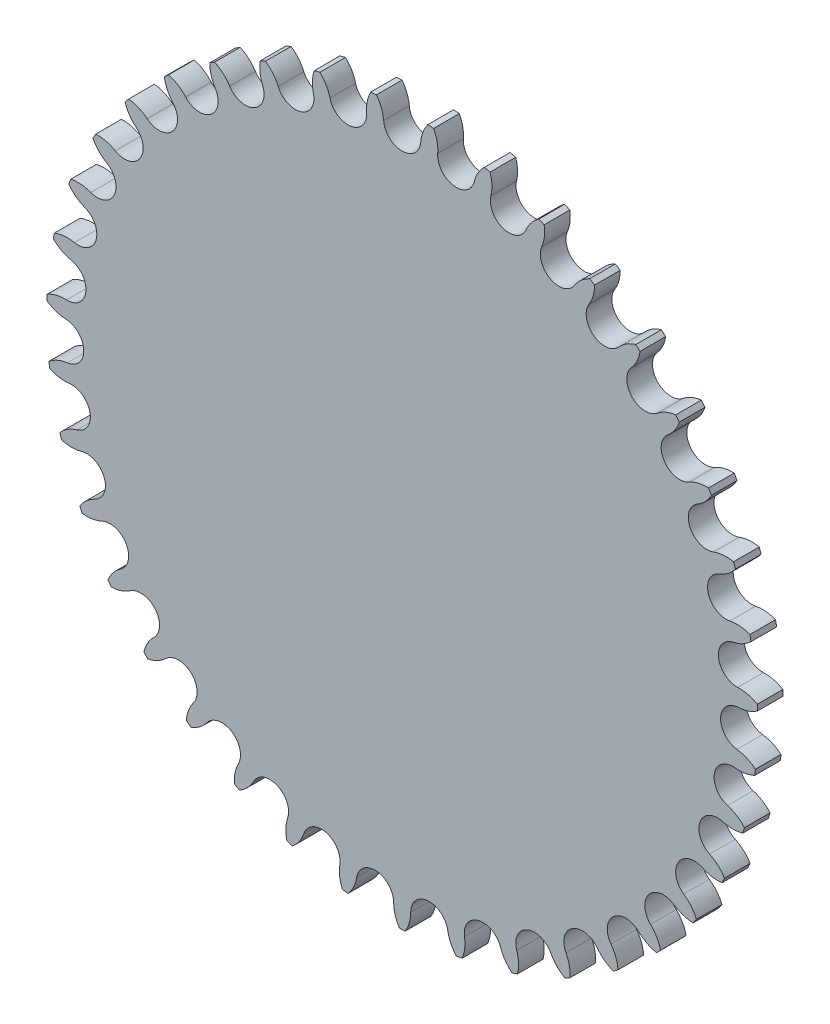
from build123d import *

# Parameters (mm, degrees)
EXTRUDE_1_DEPTH          = 6
PATTERN_CIRCULAR_1_COUNT = 39


with BuildPart() as part:
    # Эскиз2 → Бобышка-Вытянуть1 (new body)
    with BuildSketch(Plane.XY):
        with BuildLine():
            Line((0, 0), (0, 74.559760518))
            ThreePointArc((0, 74.559760518), (2.952955642, 75.713810975), (4.340878077, 78.564328611))
            ThreePointArc((4.340878077, 78.564328611), (4.866256586, 80.878637251), (6.021857466, 82.951469531))
            ThreePointArc((6.021857466, 82.951469531), (6.69238525, 82.900066612), (7.362475483, 82.843243656))
            ThreePointArc((7.362475483, 82.843243656), (8.170605955, 80.611882592), (8.317939736, 78.243267002))
            ThreePointArc((8.317939736, 78.243267002), (9.230633755, 75.207024405), (11.960226685, 73.594231202))
            Line((11.960226685, 73.594231202), (0, 0))
        make_face()
    extrude_1 = extrude(amount=EXTRUDE_1_DEPTH)

    # Круговой массив1: Бобышка-Вытянуть1 ×39 about axis
    pattern_circular_1_axis = Axis((0, 0, 0), (0, 0, 1))
    for i in range(1, PATTERN_CIRCULAR_1_COUNT):
        add(extrude_1.rotate(pattern_circular_1_axis, i * 360 / PATTERN_CIRCULAR_1_COUNT))


solid = part.part
